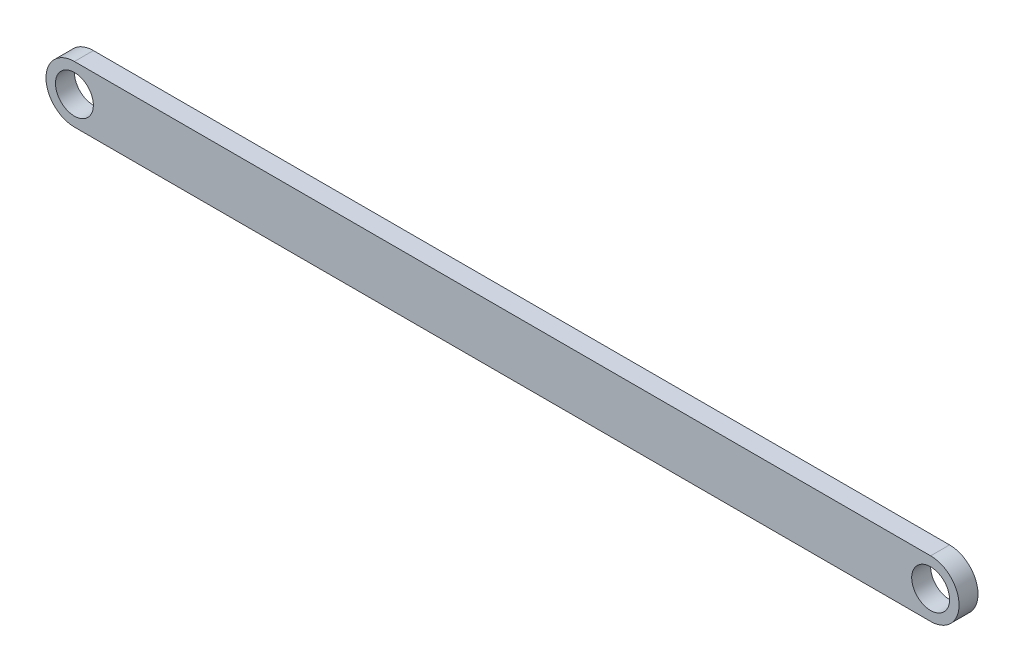
from build123d import *

# Parameters (mm, degrees)
SKETCH1_W           = 241
SKETCH1_H           = 15
BOSS_EXTRUDE1_DEPTH = 5
SKETCH2_R           = 5
CUT_EXTRUDE2_DEPTH  = 5


with BuildPart() as part:
    # Sketch1 → Boss-Extrude1 (new body)
    with BuildSketch(Plane.XY):
        with Locations((25.298972138, 7.5)):
            Rectangle(SKETCH1_W, SKETCH1_H)
    extrude(amount=BOSS_EXTRUDE1_DEPTH)

    # Sketch2 → Cut-Extrude2 (cut)
    with BuildSketch(Plane.XY.offset(5)):
        with Locations((-87.701027862, 7.5)):
            Circle(SKETCH2_R)
        with BuildLine():
            Line((-87.701027825, 15), (-95.201027862, 15))
            Line((-95.201027862, 15), (-95.201027862, 7.5))
            ThreePointArc((-95.201027862, 7.5), (-93.004328708, 12.803300872), (-87.701027825, 15))
        make_face()
        with BuildLine():
            ThreePointArc((-87.701027862, 0), (-93.004328721, 2.196699141), (-95.201027862, 7.5))
            Line((-95.201027862, 7.5), (-95.201027862, 0))
            Line((-95.201027862, 0), (-87.701027862, 0))
        make_face()
        with Locations((138.298972138, 7.5)):
            Circle(SKETCH2_R)
        with BuildLine():
            Line((145.798972138, 15), (138.298972138, 15))
            ThreePointArc((138.298972138, 15), (143.602272997, 12.803300859), (145.798972138, 7.5))
            Line((145.798972138, 7.5), (145.798972138, 15))
        make_face()
        with BuildLine():
            ThreePointArc((145.798972138, 7.5), (143.602272997, 2.196699141), (138.298972138, 0))
            Line((138.298972138, 0), (145.798972138, 0))
            Line((145.798972138, 0), (145.798972138, 7.5))
        make_face()
    extrude(amount=-CUT_EXTRUDE2_DEPTH, mode=Mode.SUBTRACT)


solid = part.part
